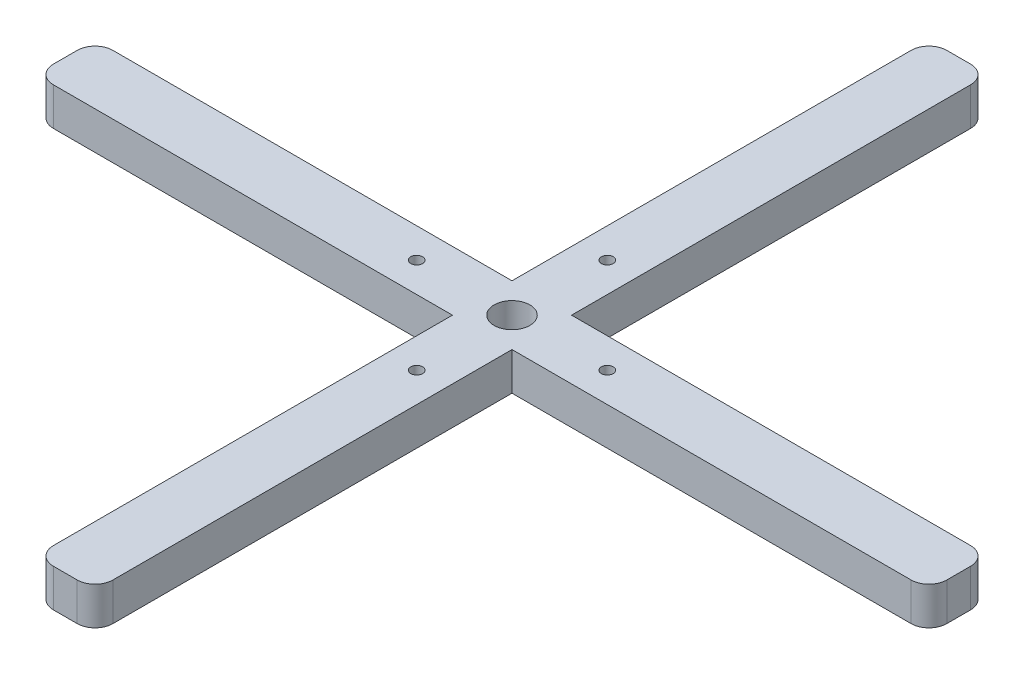
from build123d import *

# Parameters (mm, degrees)
MAIN_SHAPE_DEPTH                = 6.35
BASE_X_HOLES_D                  = 1.9939
BASE_X_HOLES_DEPTH              = 7.67
BASE_X_HOLES_TIP                = 0.599027994
FILLET1_R                       = 3
SKETCH5_R                       = 3
CUTOUT_FOR_MOUNTING_SCREW_DEPTH = 213.227054119


with BuildPart() as part:
    # Sketch1 → main shape (new body)
    with BuildSketch(Plane(origin=(0, 0, 0), x_dir=(1, 0, 0), z_dir=(0, 1, 0))):
        Polygon((80, 80), (150, 80), (150, 70), (80, 70), (80, 0), (70, 0), (70, 70), (0, 70), (0, 80), (70, 80), (70, 150), (80, 150), align=None)
    extrude(amount=MAIN_SHAPE_DEPTH)

    # base X holes
    with Locations(Plane(origin=(0, 6.35, 0), x_dir=(-1, 0, 0), z_dir=(0, 1, 0))):
        with Locations((-75, -91), (-59, -75), (-75, -59), (-91, -75)):
            Hole(BASE_X_HOLES_D / 2, depth=BASE_X_HOLES_DEPTH)
            with Locations((0, 0, -(BASE_X_HOLES_DEPTH + BASE_X_HOLES_TIP / 2))):  # 118° drill point
                Cone(0, BASE_X_HOLES_D / 2, BASE_X_HOLES_TIP, mode=Mode.SUBTRACT)

    # Fillet1
    fillet1_edges = [part.edges().sort_by_distance(p)[0] for p in [
        (70, 3.175, 0),
        (80, 3.175, 0),
        (150, 3.175, -70),
        (150, 3.175, -80),
        (80, 3.175, -150),
        (70, 3.175, -150),
        (0, 3.175, -80),
        (0, 3.175, -70),
    ]]
    fillet(fillet1_edges, radius=FILLET1_R)

    # Sketch5 → cutout for mounting screw (cut, through all)
    with BuildSketch(Plane(origin=(0, 0, 0), x_dir=(1, 0, 0), z_dir=(0, 1, 0))):
        with Locations((75, 75)):
            Circle(SKETCH5_R)
    extrude(amount=CUTOUT_FOR_MOUNTING_SCREW_DEPTH, mode=Mode.SUBTRACT)


solid = part.part
